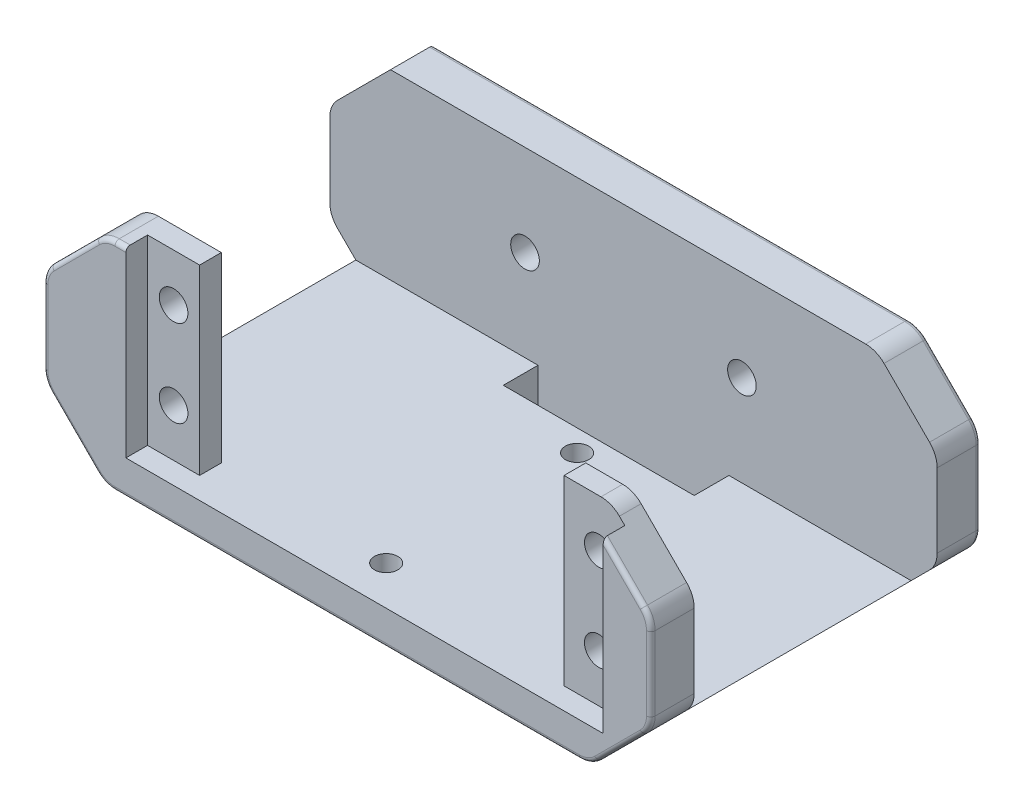
from build123d import *

# Parameters (mm, degrees)
EXTRUDE_1_DEPTH     = 38
SKETCH_2_W          = 70
SKETCH_2_H          = 28
CUT_EXTRUDE_1_DEPTH = 21
SKETCH_3_R          = 1.65
SKETCH_3_W          = 42
SKETCH_3_H          = 21
CUT_EXTRUDE_2_DEPTH = 20
SKETCH_5_R          = 1.65
CUT_EXTRUDE_3_DEPTH = 10
SKETCH_7_W          = 55
SKETCH_7_H          = 25.515470347
CUT_EXTRUDE_4_DEPTH = 2.5
FILLET_1_R          = 3
FILLET_2_R          = 0.5
SKETCH_8_R          = 1.35
SKETCH_8_W          = 22
SKETCH_8_H          = 4
CUT_EXTRUDE_5_DEPTH = 5


with BuildPart() as part:
    # 草图1 → 凸台-拉伸1 (new body)
    with BuildSketch(Plane.XY):
        Polygon((7, 0), (63, 0), (70, 7), (70, 18), (63, 25), (7, 25), (0, 18), (0, 7), align=None)
    extrude(amount=EXTRUDE_1_DEPTH)

    # 草图2 → 切除-拉伸1 (cut)
    with BuildSketch(Plane(origin=(0, 25, 0), x_dir=(1, 0, 0), z_dir=(0, 1, 0))):
        with Locations((35, -19)):
            Rectangle(SKETCH_2_W, SKETCH_2_H)
    extrude(amount=-CUT_EXTRUDE_1_DEPTH, mode=Mode.SUBTRACT)

    # 草图3 → 切除-拉伸2 (cut)
    with BuildSketch(Plane.XY.offset(38)):
        with Locations((12.5, 19.5)):
            Circle(SKETCH_3_R)
        with Locations((12.5, 9.5)):
            Circle(SKETCH_3_R)
        with Locations((61.5, 19.5)):
            Circle(SKETCH_3_R)
        with Locations((61.5, 9.5)):
            Circle(SKETCH_3_R)
        with Locations((36.5, 14.5)):
            Rectangle(SKETCH_3_W, SKETCH_3_H)
    extrude(amount=-CUT_EXTRUDE_2_DEPTH, mode=Mode.SUBTRACT)

    # 草图5 → 切除-拉伸3 (cut)
    with BuildSketch(Plane(origin=(0, 0, 0), x_dir=(-1, 0, 0), z_dir=(0, 0, -1))):
        with Locations((-22.5, 14.5)):
            Circle(SKETCH_5_R)
        with Locations((-47.5, 14.5)):
            Circle(SKETCH_5_R)
    extrude(amount=-CUT_EXTRUDE_3_DEPTH, mode=Mode.SUBTRACT)

    # 草图7 → 切除-拉伸4 (cut)
    with BuildSketch(Plane.XY.offset(38)):
        with Locations((37, 16.757735174)):
            Rectangle(SKETCH_7_W, SKETCH_7_H)
    extrude(amount=-CUT_EXTRUDE_4_DEPTH, mode=Mode.SUBTRACT)

    # 圆角1
    fillet_1_edges = [part.edges().sort_by_distance(p)[0] for p in [
        (63, 25, 34.25),
        (0, 7, 35.5),
        (0, 18, 35.5),
        (7, 25, 35.5),
        (70, 18, 35.5),
        (70, 7, 35.5),
        (63, 0, 19),
        (7, 0, 19),
        (0, 7, 2.5),
        (0, 18, 2.5),
        (63, 25, 2.5),
        (70, 18, 2.5),
        (70, 7, 2.5),
    ]]
    fillet(fillet_1_edges, radius=FILLET_1_R)

    # 圆角2
    fillet_2_edges = [part.edges().sort_by_distance(p)[0] for p in [
        (8.871320344, 25, 38),
        (66.810660172, 21.189339828, 38),
        (34.378679656, 25, 0),
        (3.5, 3.5, 0),
        (0, 12.5, 0),
        (66.5, 21.5, 0),
        (70, 12.5, 0),
        (66.5, 3.5, 0),
        (35, 0, 0),
        (7.09459039, 0.228361402, 0),
        (0.228361402, 7.09459039, 0),
        (0.228361402, 17.90540961, 0),
        (62.90540961, 0.228361402, 0),
        (69.771638598, 7.09459039, 0),
        (69.771638598, 17.90540961, 0),
        (62.90540961, 24.771638598, 0),
        (70, 12.5, 38),
        (3.5, 21.5, 38),
        (0, 12.5, 38),
        (3.5, 3.5, 38),
        (35, 0, 38),
        (66.5, 3.5, 38),
        (7.09459039, 0.228361402, 38),
        (0.228361402, 7.09459039, 38),
        (0.228361402, 17.90540961, 38),
        (7.09459039, 24.771638598, 38),
        (62.90540961, 0.228361402, 38),
        (69.771638598, 7.09459039, 38),
        (69.771638598, 17.90540961, 38),
        (3.939339828, 21.939339828, 0),
    ]]
    fillet(fillet_2_edges, radius=FILLET_2_R)

    # 草图8 → 切除-拉伸5 (cut, through all)
    with BuildSketch(Plane(origin=(0, 4, 0), x_dir=(1, 0, 0), z_dir=(0, 1, 0))):
        with Locations((35, -11.5)):
            Circle(SKETCH_8_R)
        with Locations((35, -33.5)):
            Circle(SKETCH_8_R)
        with Locations((35, -7)):
            Rectangle(SKETCH_8_W, SKETCH_8_H)
    extrude(amount=-CUT_EXTRUDE_5_DEPTH, mode=Mode.SUBTRACT)


solid = part.part
